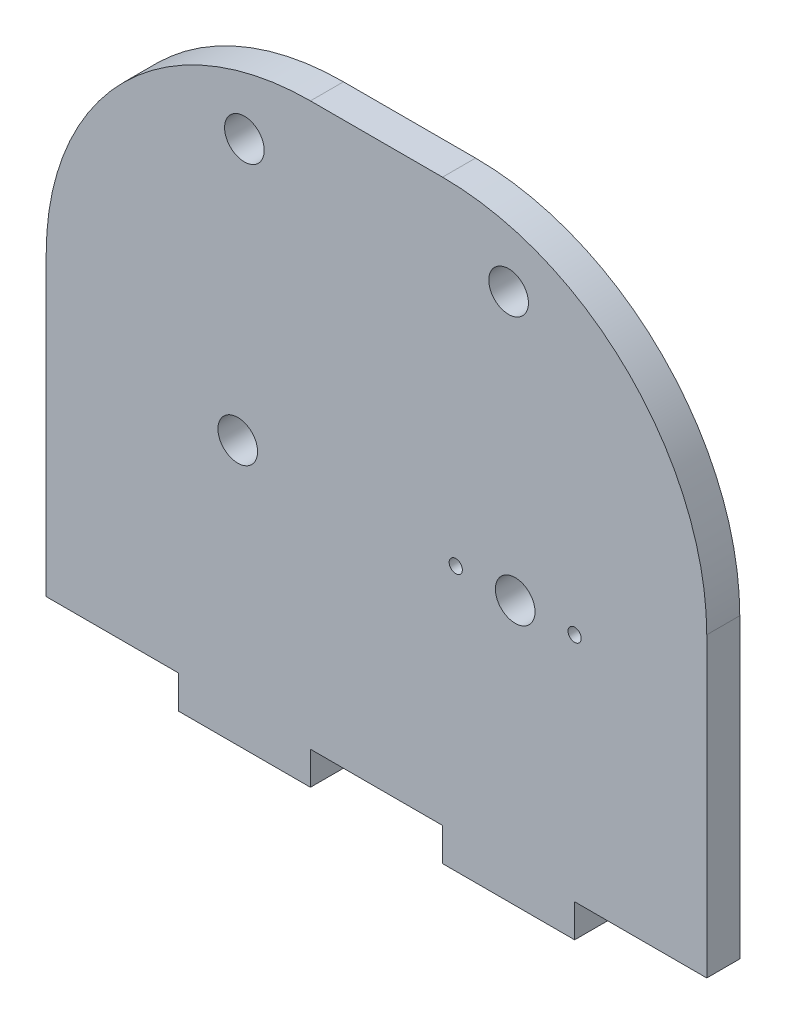
from build123d import *

# Parameters (mm, degrees)
CROQUIS1_R              = 1.5
CROQUIS1_R_2            = 0.5
SALIENTE_EXTRUIR1_DEPTH = 2.5


with BuildPart() as part:
    # Croquis1 → Saliente-Extruir1 (new body)
    with BuildSketch(Plane.XY):
        with BuildLine():
            Line((-25, -15), (-25, -5))
            ThreePointArc((-25, -5), (-19.142135624, 9.142135624), (-5, 15))
            Line((-5, 15), (5, 15))
            ThreePointArc((5, 15), (19.142135624, 9.142135624), (25, -5))
            Line((25, -5), (25, -15))
            Line((25, -15), (25, -27.5))
            Line((25, -27.5), (15, -27.5))
            Line((15, -27.5), (15, -30))
            Line((15, -30), (5, -30))
            Line((5, -30), (5, -27.5))
            Line((5, -27.5), (-5, -27.5))
            Line((-5, -27.5), (-5, -30))
            Line((-5, -30), (-15, -30))
            Line((-15, -30), (-15, -27.5))
            Line((-15, -27.5), (-25, -27.5))
            Line((-25, -27.5), (-25, -15))
        make_face()
        with Locations((-10, 10)):
            Circle(CROQUIS1_R, mode=Mode.SUBTRACT)
        with Locations((10, 10)):
            Circle(CROQUIS1_R, mode=Mode.SUBTRACT)
        with Locations((-10.5, -10)):
            Circle(CROQUIS1_R, mode=Mode.SUBTRACT)
        with Locations((10.5, -10)):
            Circle(CROQUIS1_R, mode=Mode.SUBTRACT)
        with Locations((15, -10)):
            Circle(CROQUIS1_R_2, mode=Mode.SUBTRACT)
        with Locations((6, -10)):
            Circle(CROQUIS1_R_2, mode=Mode.SUBTRACT)
    extrude(amount=SALIENTE_EXTRUIR1_DEPTH)


solid = part.part
